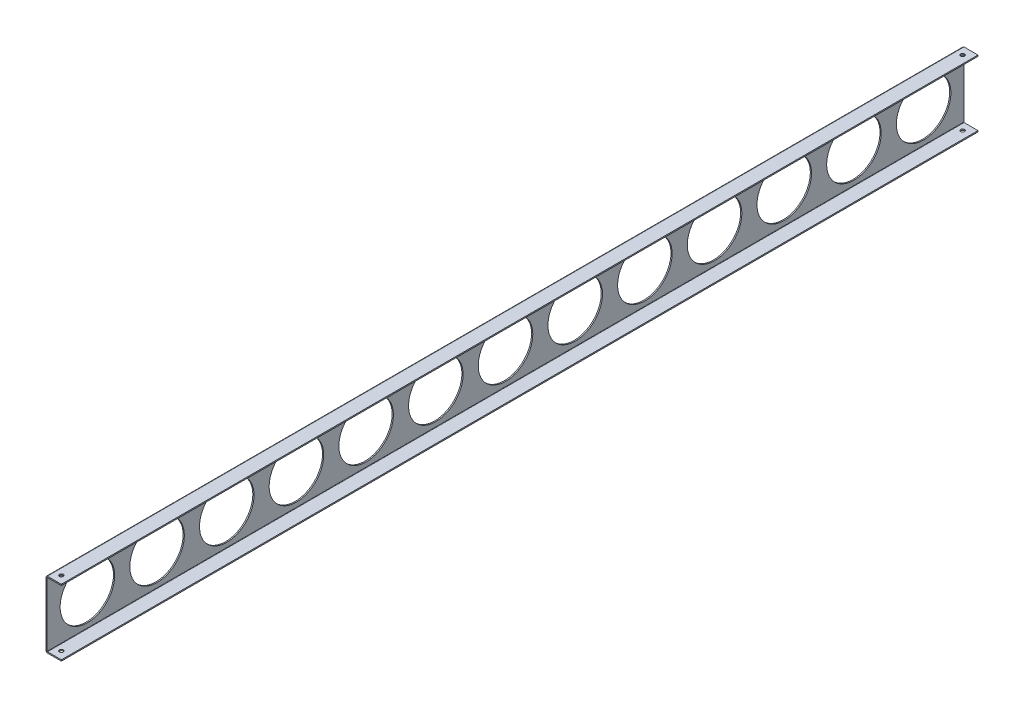
from build123d import *

# Parameters (mm, degrees)
EXTRUDE_THIN1_DEPTH = 756.30962295
SKETCH2_R           = 45
EXTRUDE1_DEPTH      = 3
LPATTERN1_COUNT     = 7
LPATTERN1_PITCH     = 115
LPATTERN2_COUNT     = 7
LPATTERN2_PITCH     = 115
SKETCH3_R           = 3.175
EXTRUDE2_DEPTH      = 111


with BuildPart() as part:
    # Sketch1 → Extrude-Thin1 (new body, symmetric)
    with BuildSketch(Plane.XY):
        with BuildLine():
            Line((25.4, 55), (2.54, 55))
            ThreePointArc((2.54, 55), (0.743948776, 54.256051224), (0, 52.46))
            Line((0, 52.46), (0, -52.46))
            ThreePointArc((0, -52.46), (0.743948776, -54.256051224), (2.54, -55))
            Line((2.54, -55), (25.4, -55))
            Line((25.4, -55), (25.4, -53))
            Line((25.4, -53), (2.54, -53))
            ThreePointArc((2.54, -53), (2.158162338, -52.841837662), (2, -52.46))
            Line((2, -52.46), (2, 52.46))
            ThreePointArc((2, 52.46), (2.158162338, 52.841837662), (2.54, 53))
            Line((2.54, 53), (25.4, 53))
            Line((25.4, 53), (25.4, 55))
        make_face()
    extrude(amount=EXTRUDE_THIN1_DEPTH, both=True)

    # Sketch2 → Extrude1 (cut, through all)
    with BuildSketch(Plane(origin=(2, 0, 0), x_dir=(0, 0, -1), z_dir=(1, 0, 0))):
        Circle(SKETCH2_R)
    extrude1 = extrude(amount=-EXTRUDE1_DEPTH, mode=Mode.SUBTRACT)

    # LPattern1: Extrude1 ×7
    with Locations(*[(0, 0, i * LPATTERN1_PITCH) for i in range(1, LPATTERN1_COUNT)]):
        add(extrude1, mode=Mode.SUBTRACT)

    # LPattern2: Extrude1 ×7
    with Locations(*[(0, 0, -i * LPATTERN2_PITCH) for i in range(1, LPATTERN2_COUNT)]):
        add(extrude1, mode=Mode.SUBTRACT)

    # Sketch3 → Extrude2 (cut, through all)
    with BuildSketch(Plane.XZ.offset(55)):
        with Locations(Location((12.7, 743.60962295, 0), (0, 0, 270))):  # turned: the seam where the file's is
            Circle(SKETCH3_R)
    extrude2 = extrude(amount=-EXTRUDE2_DEPTH, mode=Mode.SUBTRACT)

    # Mirror1: Extrude2 across plane
    add(extrude2.mirror(Plane.XY), mode=Mode.SUBTRACT)


solid = part.part
